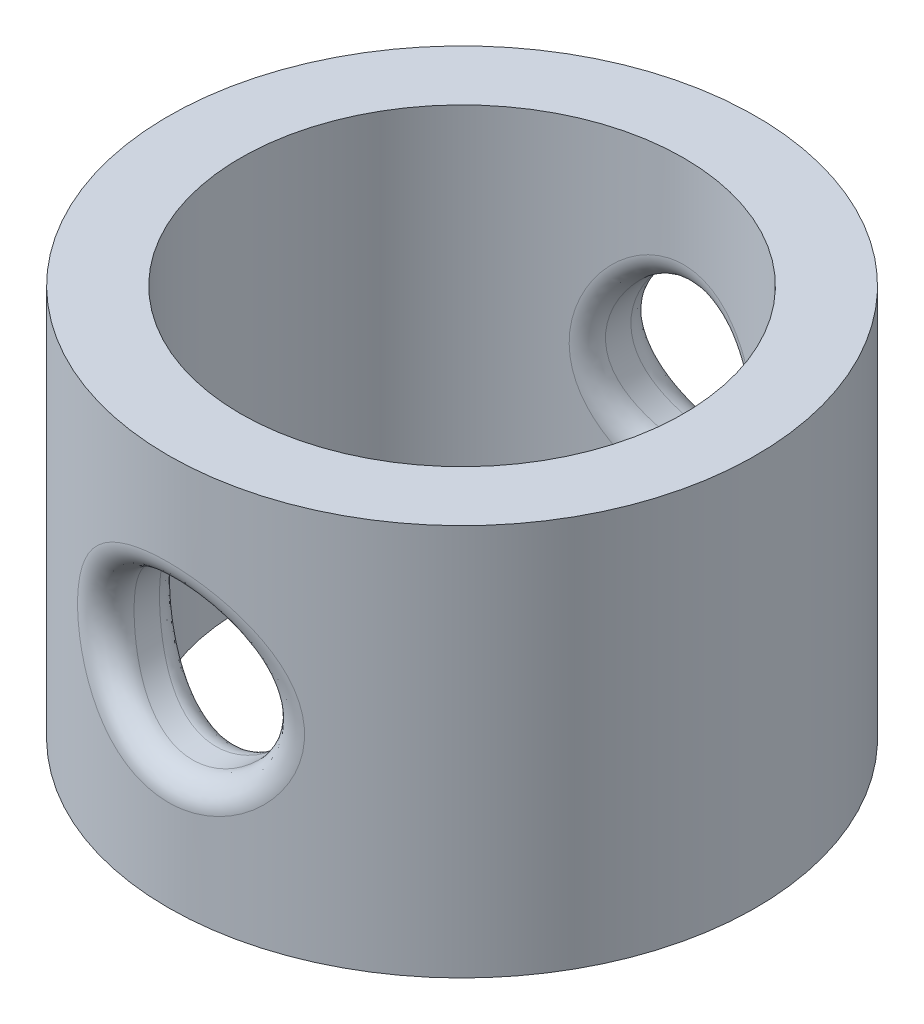
from build123d import *

# Parameters (mm, degrees)
SKETCH1_R               = 6
SKETCH1_R_2             = 4.525
BOSS_EXTRUDE1_DEPTH     = 8
SKETCH2_R               = 1.625
CUT_EXTRUDE1_DEPTH      = 7
CUT_EXTRUDE1_DEPTH_BACK = 7
FILLET1_R               = 0.5


with BuildPart() as part:
    # Sketch1 → Boss-Extrude1 (new body)
    with BuildSketch(Plane(origin=(0, 0, 0), x_dir=(1, 0, 0), z_dir=(0, 1, 0))):
        Circle(SKETCH1_R)
        Circle(SKETCH1_R_2, mode=Mode.SUBTRACT)
    extrude(amount=BOSS_EXTRUDE1_DEPTH)

    # Sketch2 → Cut-Extrude1 (cut, two sides)
    with BuildSketch(Plane.XY) as cut_extrude1_sk:
        with Locations((0, 3.987519755)):
            Circle(SKETCH2_R)
    extrude(amount=CUT_EXTRUDE1_DEPTH, mode=Mode.SUBTRACT)
    extrude(cut_extrude1_sk.sketch, amount=-CUT_EXTRUDE1_DEPTH_BACK, mode=Mode.SUBTRACT)

    # Fillet1
    fillet1_edges = [part.edges().sort_by_distance(p)[0] for p in [
        (-1.624999996, 3.987519756, -5.775757533),
        (-1.624999996, 3.987519756, 5.775757533),
        (-1.625, 3.987519755, 4.223150483),
        (-1.625, 3.987519755, -4.223150483),
    ]]
    fillet(fillet1_edges, radius=FILLET1_R)


solid = part.part
